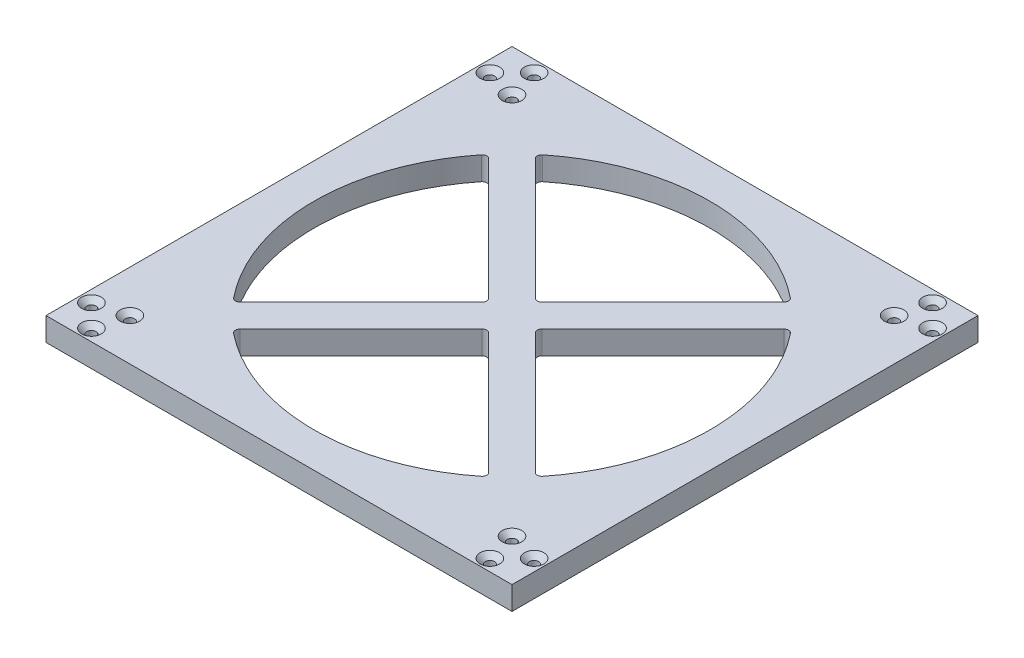
from build123d import *

# Parameters (mm, degrees)
SKETCH2_W                             = 100
SKETCH2_H                             = 100
BOSS_EXTRUDE2_DEPTH                   = 5
TAP_DRILL_FOR_M2X0_4_TAP1_D           = 2
TAP_DRILL_FOR_M2X0_4_TAP1_CSINK_D     = 4.2
TAP_DRILL_FOR_M2X0_4_TAP1_CSINK_ANGLE = 90
TAP_DRILL_FOR_M2X0_4_TAP2_D           = 2
TAP_DRILL_FOR_M2X0_4_TAP2_CSINK_D     = 4.2
TAP_DRILL_FOR_M2X0_4_TAP2_CSINK_ANGLE = 90
CIRPATTERN1_COUNT                     = 4


with BuildPart() as part:
    # Sketch2 → Boss-Extrude2 (new body)
    with BuildSketch(Plane(origin=(0, 0, 0), x_dir=(1, 0, 0), z_dir=(0, 1, 0))):
        with Locations((50, 50)):
            Rectangle(SKETCH2_W, SKETCH2_H)
        with BuildLine():
            Line((23.330847354, 81.669152646), (49.292893219, 55.707106781))
            ThreePointArc((49.292893219, 55.707106781), (50, 55.414213562), (50.707106781, 55.707106781))
            Line((50.707106781, 55.707106781), (76.669152646, 81.669152646))
            ThreePointArc((76.669152646, 81.669152646), (76.96054722, 82.430986431), (76.587637332, 83.156410257))
            ThreePointArc((76.587637332, 83.156410257), (50, 92.5), (23.412362668, 83.156410257))
            ThreePointArc((23.412362668, 83.156410257), (23.03945278, 82.430986431), (23.330847354, 81.669152646))
        make_face(mode=Mode.SUBTRACT)
        with BuildLine():
            Line((81.669152646, 76.669152646), (55.707106781, 50.707106781))
            ThreePointArc((55.707106781, 50.707106781), (55.414213562, 50), (55.707106781, 49.292893219))
            Line((55.707106781, 49.292893219), (81.669152646, 23.330847354))
            ThreePointArc((81.669152646, 23.330847354), (82.430986431, 23.03945278), (83.156410257, 23.412362668))
            ThreePointArc((83.156410257, 23.412362668), (92.5, 50), (83.156410257, 76.587637332))
            ThreePointArc((83.156410257, 76.587637332), (82.430986431, 76.96054722), (81.669152646, 76.669152646))
        make_face(mode=Mode.SUBTRACT)
        with BuildLine():
            Line((76.669152646, 18.330847354), (50.707106781, 44.292893219))
            ThreePointArc((50.707106781, 44.292893219), (50, 44.585786438), (49.292893219, 44.292893219))
            Line((49.292893219, 44.292893219), (23.330847354, 18.330847354))
            ThreePointArc((23.330847354, 18.330847354), (23.03945278, 17.569013569), (23.412362668, 16.843589743))
            ThreePointArc((23.412362668, 16.843589743), (50, 7.5), (76.587637332, 16.843589743))
            ThreePointArc((76.587637332, 16.843589743), (76.96054722, 17.569013569), (76.669152646, 18.330847354))
        make_face(mode=Mode.SUBTRACT)
        with BuildLine():
            Line((18.330847354, 23.330847354), (44.292893219, 49.292893219))
            ThreePointArc((44.292893219, 49.292893219), (44.585786438, 50), (44.292893219, 50.707106781))
            Line((44.292893219, 50.707106781), (18.330847354, 76.669152646))
            ThreePointArc((18.330847354, 76.669152646), (17.569013569, 76.96054722), (16.843589743, 76.587637332))
            ThreePointArc((16.843589743, 76.587637332), (7.5, 50), (16.843589743, 23.412362668))
            ThreePointArc((16.843589743, 23.412362668), (17.569013569, 23.03945278), (18.330847354, 23.330847354))
        make_face(mode=Mode.SUBTRACT)
    extrude(amount=BOSS_EXTRUDE2_DEPTH)

    # Tap Drill for M2x0.4 Tap1 (through all)
    with Locations(Plane(origin=(9, 5, -9), x_dir=(0, 0, 1), z_dir=(0, 1, 0))):
        with Locations((0, 0), (-82, 0), (-82, 82), (0, 82)):
            CounterSinkHole(TAP_DRILL_FOR_M2X0_4_TAP1_D / 2, TAP_DRILL_FOR_M2X0_4_TAP1_CSINK_D / 2, counter_sink_angle=TAP_DRILL_FOR_M2X0_4_TAP1_CSINK_ANGLE)

    # Tap Drill for M2x0.4 Tap2 (through all)
    with Locations(Plane(origin=(2.5, 5, -7.25), x_dir=(0, 0, 1), z_dir=(0, 1, 0))):
        with Locations((0, 0), (4.75, 4.75)):
            tap_drill_for_m2x0_4_tap2 = CounterSinkHole(TAP_DRILL_FOR_M2X0_4_TAP2_D / 2, TAP_DRILL_FOR_M2X0_4_TAP2_CSINK_D / 2, counter_sink_angle=TAP_DRILL_FOR_M2X0_4_TAP2_CSINK_ANGLE)

    # CirPattern1: Tap Drill for M2x0.4 Tap2 ×4 about axis
    cirpattern1_axis = Axis((50, 5, -50), (0, -1, 0))
    for i in range(1, CIRPATTERN1_COUNT):
        add(tap_drill_for_m2x0_4_tap2.rotate(cirpattern1_axis, i * 360 / CIRPATTERN1_COUNT), mode=Mode.SUBTRACT)


solid = part.part
